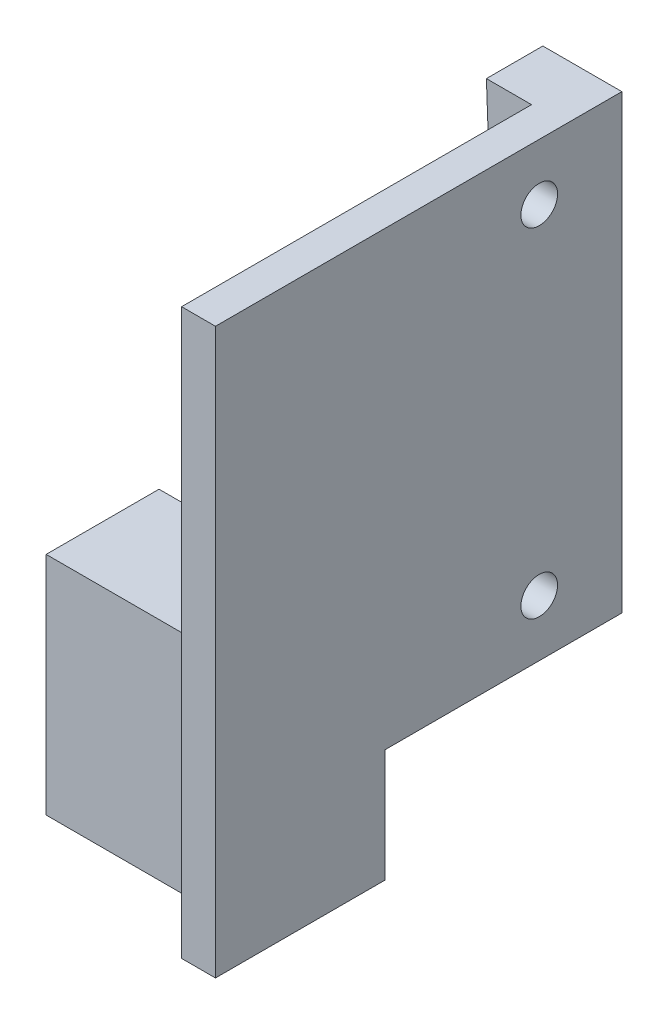
from build123d import *

# Parameters (mm, degrees)
ESQUISSE1_W             = 7
ESQUISSE1_H             = 40
BOSS_EXTRU_1_DEPTH      = 5
ENL_V_MAT_EXTRU_1_DEPTH = 5
ESQUISSE3_W             = 3
ESQUISSE3_H             = 40
BOSS_EXTRU_2_DEPTH      = 6
ESQUISSE5_W             = 3
ESQUISSE5_H             = 10
BOSS_EXTRU_3_DEPTH      = 25
ESQUISSE4_R             = 1.625
ENL_V_MAT_EXTRU_2_DEPTH = 4
ESQUISSE9_W             = 3
ESQUISSE9_H             = 30
BOSS_EXTRU_5_DEPTH      = 25
ESQUISSE10_W            = 3
ESQUISSE10_H            = 15
BOSS_EXTRU_6_DEPTH      = 10
ESQUISSE11_W            = 10
ESQUISSE11_H            = 20
BOSS_EXTRU_7_DEPTH      = 17
ESQUISSE12_R            = 2.6
ENL_V_MAT_EXTRU_3_DEPTH = 5


with BuildPart() as part:
    # Esquisse1 → Boss.-Extru.1 (new body)
    with BuildSketch(Plane.XY):
        with Locations((3.5, -20)):
            Rectangle(ESQUISSE1_W, ESQUISSE1_H)
    extrude(amount=BOSS_EXTRU_1_DEPTH)

    # Esquisse2 → Enlèv. mat.-Extru.1 (cut)
    with BuildSketch(Plane.XY.offset(5)):
        Polygon((0, -40), (0, 0), (1.5, -40), align=None)
    extrude(amount=-ENL_V_MAT_EXTRU_1_DEPTH, mode=Mode.SUBTRACT)

    # Esquisse3 → Boss.-Extru.2 (add)
    with BuildSketch(Plane.XY.offset(5)):
        with Locations((5.5, -20)):
            Rectangle(ESQUISSE3_W, ESQUISSE3_H)
    extrude(amount=BOSS_EXTRU_2_DEPTH)

    # Esquisse5 → Boss.-Extru.3 (add)
    with BuildSketch(Plane.XY.offset(11)):
        with Locations((5.5, -5)):
            Rectangle(ESQUISSE5_W, ESQUISSE5_H)
    extrude(amount=BOSS_EXTRU_3_DEPTH)

    # Esquisse4 → Enlèv. mat.-Extru.2 (cut, through all)
    with BuildSketch(Plane.ZY.offset(-4)):
        with Locations((7.320815767, -35)):
            Circle(ESQUISSE4_R)
        with Locations((7.320815767, -5)):
            Circle(ESQUISSE4_R)
    extrude(amount=-ENL_V_MAT_EXTRU_2_DEPTH, mode=Mode.SUBTRACT)

    # Esquisse9 → Boss.-Extru.5 (add)
    with BuildSketch(Plane.XY.offset(11)):
        with Locations((5.5, -25)):
            Rectangle(ESQUISSE9_W, ESQUISSE9_H)
    extrude(amount=BOSS_EXTRU_5_DEPTH)

    # Esquisse10 → Boss.-Extru.6 (add)
    with BuildSketch(Plane.XZ.offset(40)):
        with Locations((5.5, 28.5)):
            Rectangle(ESQUISSE10_W, ESQUISSE10_H)
    extrude(amount=BOSS_EXTRU_6_DEPTH)

    # Esquisse11 → Boss.-Extru.7 (add)
    with BuildSketch(Plane.ZY.offset(-4)):
        with Locations((26, -40)):
            Rectangle(ESQUISSE11_W, ESQUISSE11_H)
    extrude(amount=BOSS_EXTRU_7_DEPTH)

    # Esquisse12 → Enlèv. mat.-Extru.3 (cut)
    with BuildSketch(Plane(origin=(0, 0, 21), x_dir=(-1, 0, 0), z_dir=(0, 0, -1))):
        with Locations((5.3, -44.1)):
            Circle(ESQUISSE12_R)
    extrude(amount=-ENL_V_MAT_EXTRU_3_DEPTH, mode=Mode.SUBTRACT)


solid = part.part
